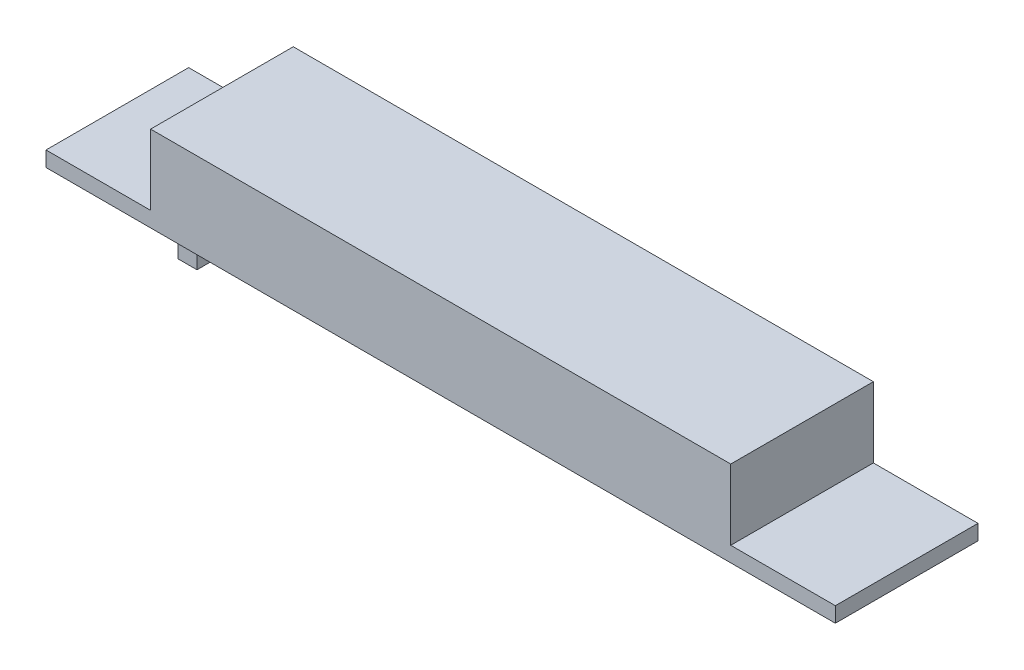
from build123d import *

# Parameters (mm, degrees)
SKETCH1_W           = 83
SKETCH1_H           = 15
BOSS_EXTRUDE1_DEPTH = 1.6
SKETCH2_W           = 61
SKETCH2_H           = 15
BOSS_EXTRUDE2_DEPTH = 7.4
SKETCH3_W           = 2
SKETCH3_H           = 13.25
BOSS_EXTRUDE3_DEPTH = 2.25


with BuildPart() as part:
    # Sketch1 → Boss-Extrude1 (new body)
    with BuildSketch(Plane(origin=(0, 0, 0), x_dir=(1, 0, 0), z_dir=(0, 1, 0))):
        Rectangle(SKETCH1_W, SKETCH1_H)
    extrude(amount=BOSS_EXTRUDE1_DEPTH)

    # Sketch2 → Boss-Extrude2 (add)
    with BuildSketch(Plane(origin=(0, 1.6, 0), x_dir=(1, 0, 0), z_dir=(0, 1, 0))):
        Rectangle(SKETCH2_W, SKETCH2_H)
    extrude(amount=BOSS_EXTRUDE2_DEPTH)

    # Sketch3 → Boss-Extrude3 (add)
    with BuildSketch(Plane(origin=(0, 0, 0), x_dir=(-1, 0, 0), z_dir=(0, -1, 0))):
        with Locations((27.5, 0)):
            Rectangle(SKETCH3_W, SKETCH3_H)
    extrude(amount=BOSS_EXTRUDE3_DEPTH)


solid = part.part
